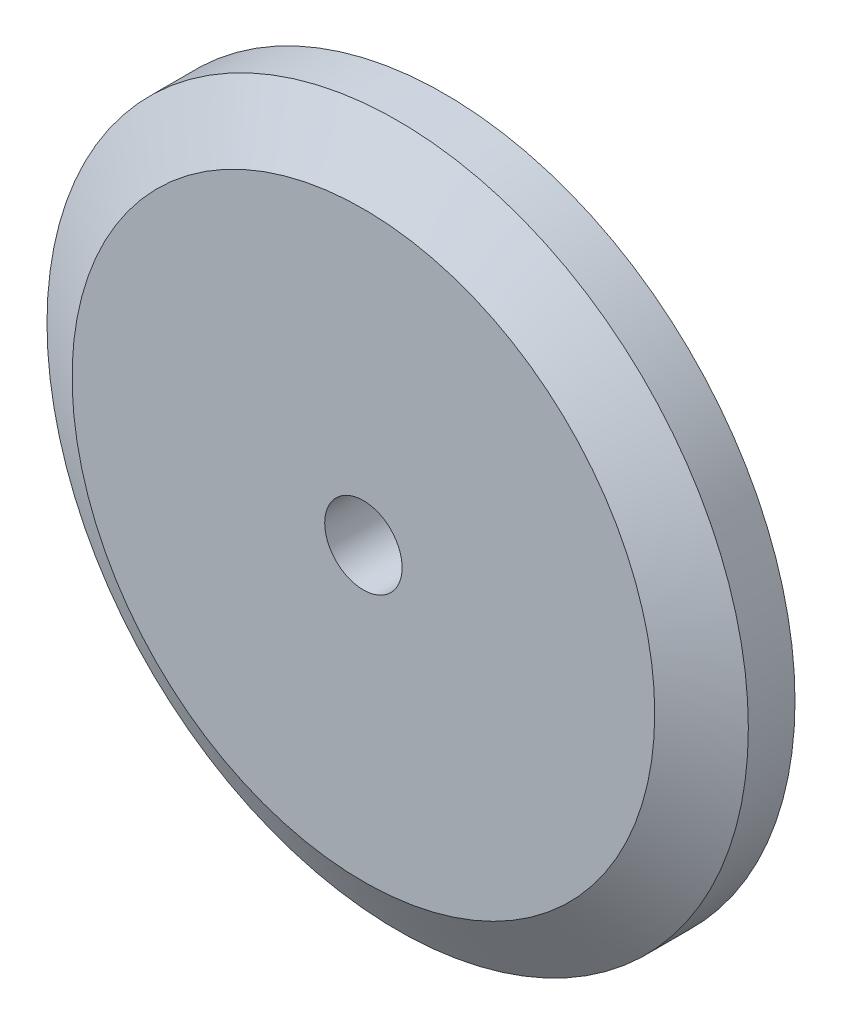
from build123d import *

# Parameters (mm, degrees)
SKETCH2_R           = 5.5
SKETCH2_R_2         = 3.923
BOSS_EXTRUDE1_DEPTH = 0.5
SKETCH3_R           = 13
SKETCH3_R_2         = 5.5
SKETCH3_R_3         = 3.923
BOSS_EXTRUDE2_DEPTH = 3
SKETCH4_R           = 1.435
CUT_EXTRUDE1_DEPTH  = 65.893162175
CHAMFER1_SIZE       = 1.27
CHAMFER1_SIZE2      = 2.199704526


with BuildPart() as part:
    # Sketch2 → Boss-Extrude1 (new body)
    with BuildSketch(Plane.XY.offset(-0.5)):
        with Locations((40.399999972, -23.75)):
            Circle(SKETCH2_R)
        with Locations((40.399999972, -23.75)):
            Circle(SKETCH2_R_2, mode=Mode.SUBTRACT)
    extrude(amount=BOSS_EXTRUDE1_DEPTH)

    # Sketch3 → Boss-Extrude2 (add)
    with BuildSketch(Plane.XY):
        with Locations((40.399999972, -23.75)):
            Circle(SKETCH3_R)
        with Locations((40.399999972, -23.75)):
            Circle(SKETCH3_R_2, mode=Mode.SUBTRACT)
        with Locations((40.399999972, -23.75)):
            Circle(SKETCH3_R_2)
        with Locations((40.399999972, -23.75)):
            Circle(SKETCH3_R_3, mode=Mode.SUBTRACT)
        with Locations((40.399999972, -23.75)):
            Circle(SKETCH3_R_3)
    extrude(amount=BOSS_EXTRUDE2_DEPTH)

    # Sketch4 → Cut-Extrude1 (cut, through all)
    with BuildSketch(Plane(origin=(0, 0, 0), x_dir=(-1, 0, 0), z_dir=(0, 0, -1))):
        with Locations((-40.399999972, -23.75)):
            Circle(SKETCH4_R)
    extrude(amount=-CUT_EXTRUDE1_DEPTH, mode=Mode.SUBTRACT)

    # Chamfer1
    chamfer1_edges = [part.edges().sort_by_distance(p)[0] for p in [
        (27.399999972, -23.75, 3),
    ]]
    chamfer1_side = [part.faces().sort_by_distance(p)[0] for p in [
        (27.399999972, -23.75, 1.5),
    ]]
    chamfer(chamfer1_edges, length=CHAMFER1_SIZE, length2=CHAMFER1_SIZE2, reference=chamfer1_side[0])


solid = part.part
